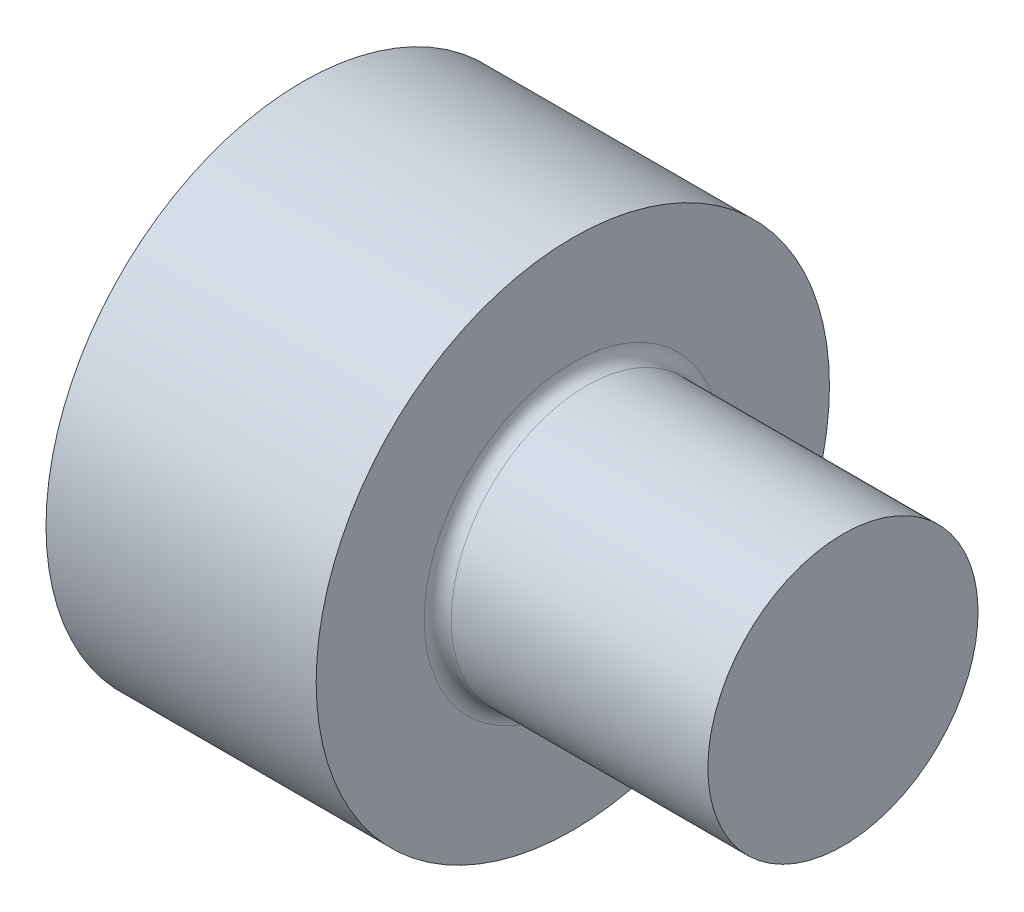
from build123d import *

# Parameters (mm, degrees)
FILLET1_R = 1


with BuildPart() as part:
    # Sketch1 → Revolve1 (revolve)
    with BuildSketch(Plane.XY):
        Polygon((0, 0), (-40, 0), (-40, 19), (-20, 19), (-20, 10), (0, 10), align=None)
    revolve(axis=Axis((0, 0, 0), (-1, 0, 0)))

    # Fillet1
    fillet1_edges = [part.edges().sort_by_distance(p)[0] for p in [
        (-20, -10, 0),
    ]]
    fillet(fillet1_edges, radius=FILLET1_R)


solid = part.part
